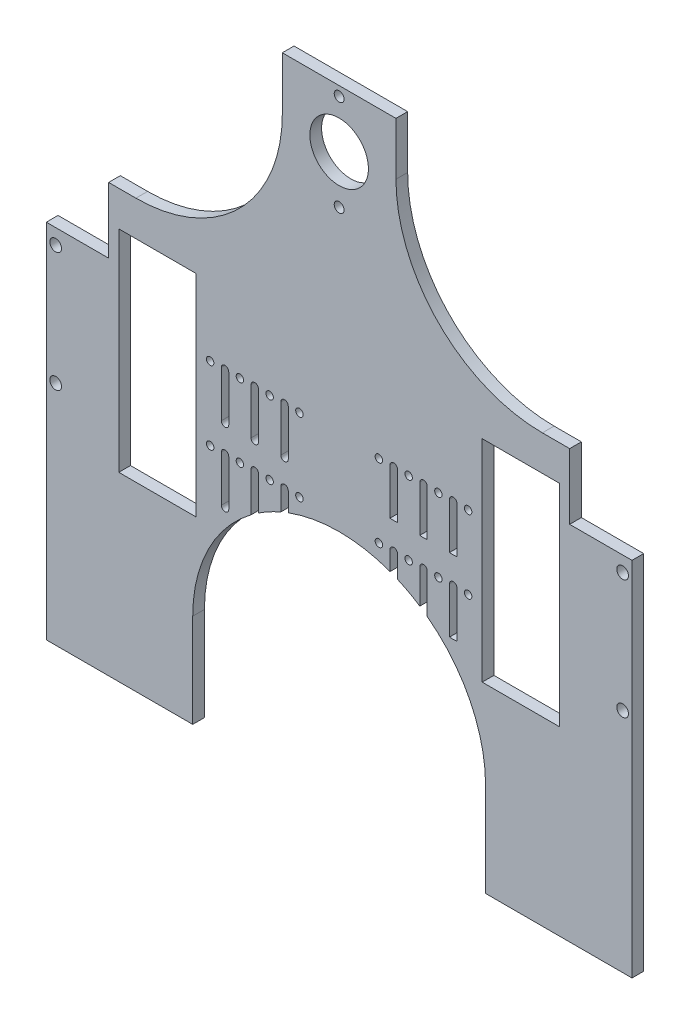
from build123d import *

# Parameters (mm, degrees)
SKETCH1_W           = 250
SKETCH1_H           = 350.4
SKETCH1_R           = 2.1
SKETCH1_R_2         = 2.5
SKETCH1_R_3         = 1.59
SKETCH1_R_4         = 12.5
SKETCH1_W_2         = 33
SKETCH1_H_2         = 90
BOSS_EXTRUDE1_DEPTH = 5
SKETCH12_W          = 250
SKETCH12_H          = 5
CUT_EXTRUDE2_DEPTH  = 83
CUT_EXTRUDE3_DEPTH  = 6
SKETCH15_W          = 20.294476706
SKETCH15_H          = 22.5
SKETCH15_W_2        = 16.246360579
CUT_EXTRUDE4_DEPTH  = 10


with BuildPart() as part:
    # Sketch1 → Boss-Extrude1 (new body)
    with BuildSketch(Plane.XY):
        with Locations((125, -175.2)):
            Rectangle(SKETCH1_W, SKETCH1_H)
        with Locations((125, -45)):
            Circle(SKETCH1_R, mode=Mode.SUBTRACT)
        with Locations((125, -4)):
            Circle(SKETCH1_R, mode=Mode.SUBTRACT)
        with Locations((246, -119.5)):
            Circle(SKETCH1_R_2, mode=Mode.SUBTRACT)
        with Locations((246, -170.5)):
            Circle(SKETCH1_R_2, mode=Mode.SUBTRACT)
        with Locations((180.06, -129.375)):
            Circle(SKETCH1_R_3, mode=Mode.SUBTRACT)
        with Locations((180.06, -160.625)):
            Circle(SKETCH1_R_3, mode=Mode.SUBTRACT)
        with Locations((125, -24.5)):
            Circle(SKETCH1_R_4, mode=Mode.SUBTRACT)
        with Locations((141.96, -129.375)):
            Circle(SKETCH1_R_3, mode=Mode.SUBTRACT)
        with Locations((154.66, -129.375)):
            Circle(SKETCH1_R_3, mode=Mode.SUBTRACT)
        with Locations((167.36, -129.375)):
            Circle(SKETCH1_R_3, mode=Mode.SUBTRACT)
        with Locations((141.96, -160.625)):
            Circle(SKETCH1_R_3, mode=Mode.SUBTRACT)
        with Locations((154.66, -160.625)):
            Circle(SKETCH1_R_3, mode=Mode.SUBTRACT)
        with Locations((167.36, -160.625)):
            Circle(SKETCH1_R_3, mode=Mode.SUBTRACT)
        with Locations((82.64, -160.625)):
            Circle(SKETCH1_R_3, mode=Mode.SUBTRACT)
        with Locations((95.34, -160.625)):
            Circle(SKETCH1_R_3, mode=Mode.SUBTRACT)
        with Locations((108.04, -160.625)):
            Circle(SKETCH1_R_3, mode=Mode.SUBTRACT)
        with Locations((82.64, -129.375)):
            Circle(SKETCH1_R_3, mode=Mode.SUBTRACT)
        with Locations((95.34, -129.375)):
            Circle(SKETCH1_R_3, mode=Mode.SUBTRACT)
        with Locations((108.04, -129.375)):
            Circle(SKETCH1_R_3, mode=Mode.SUBTRACT)
        with Locations((69.94, -160.625)):
            Circle(SKETCH1_R_3, mode=Mode.SUBTRACT)
        with Locations((69.94, -129.375)):
            Circle(SKETCH1_R_3, mode=Mode.SUBTRACT)
        with Locations((4, -170.5)):
            Circle(SKETCH1_R_2, mode=Mode.SUBTRACT)
        with Locations((4, -119.5)):
            Circle(SKETCH1_R_2, mode=Mode.SUBTRACT)
        with Locations((202.56, -145)):
            Rectangle(SKETCH1_W_2, SKETCH1_H_2, mode=Mode.SUBTRACT)
        with BuildLine():
            Line((146.7225, -129.375), (146.7225, -149.054634918))
            ThreePointArc((146.7225, -149.054634918), (148.31, -149.140223925), (149.8975, -149.054634918))
            Line((149.8975, -149.054634918), (149.8975, -129.375))
            ThreePointArc((149.8975, -129.375), (148.31, -127.7875), (146.7225, -129.375))
        make_face(mode=Mode.SUBTRACT)
        with BuildLine():
            Line((159.42, -129.375), (159.42, -149.054634918))
            ThreePointArc((159.42, -149.054634918), (161.01, -149.140492925), (162.6, -149.054634918))
            Line((162.6, -149.054634918), (162.6, -129.375))
            ThreePointArc((162.6, -129.375), (161.01, -127.785), (159.42, -129.375))
        make_face(mode=Mode.SUBTRACT)
        with BuildLine():
            Line((172.12, -129.375), (172.12, -149.054634918))
            ThreePointArc((172.12, -149.054634918), (173.71, -149.140492925), (175.3, -149.054634918))
            Line((175.3, -149.054634918), (175.3, -129.375))
            ThreePointArc((175.3, -129.375), (173.71, -127.785), (172.12, -129.375))
        make_face(mode=Mode.SUBTRACT)
        with BuildLine():
            Line((146.7225, -160.625), (146.7225, -180.304634918))
            ThreePointArc((146.7225, -180.304634918), (148.31, -180.390223925), (149.8975, -180.304634918))
            Line((149.8975, -180.304634918), (149.8975, -160.625))
            ThreePointArc((149.8975, -160.625), (148.31, -159.0375), (146.7225, -160.625))
        make_face(mode=Mode.SUBTRACT)
        with BuildLine():
            Line((159.42, -160.625), (159.42, -180.304634918))
            ThreePointArc((159.42, -180.304634918), (161.01, -180.390492925), (162.6, -180.304634918))
            Line((162.6, -180.304634918), (162.6, -160.625))
            ThreePointArc((162.6, -160.625), (161.01, -159.035), (159.42, -160.625))
        make_face(mode=Mode.SUBTRACT)
        with BuildLine():
            Line((172.12, -160.625), (172.12, -180.304634918))
            ThreePointArc((172.12, -180.304634918), (173.71, -180.390492925), (175.3, -180.304634918))
            Line((175.3, -180.304634918), (175.3, -160.625))
            ThreePointArc((175.3, -160.625), (173.71, -159.035), (172.12, -160.625))
        make_face(mode=Mode.SUBTRACT)
        with BuildLine():
            Line((103.2775, -129.375), (103.2775, -149.054634918))
            ThreePointArc((103.2775, -149.054634918), (101.69, -150.642134918), (100.1025, -149.054634918))
            Line((100.1025, -149.054634918), (100.1025, -129.375))
            ThreePointArc((100.1025, -129.375), (101.69, -127.7875), (103.2775, -129.375))
        make_face(mode=Mode.SUBTRACT)
        with BuildLine():
            Line((90.58, -129.375), (90.58, -149.054634918))
            ThreePointArc((90.58, -149.054634918), (88.99, -150.644634918), (87.4, -149.054634918))
            Line((87.4, -149.054634918), (87.4, -129.375))
            ThreePointArc((87.4, -129.375), (88.99, -127.785), (90.58, -129.375))
        make_face(mode=Mode.SUBTRACT)
        with BuildLine():
            Line((77.88, -129.375), (77.88, -149.054634918))
            ThreePointArc((77.88, -149.054634918), (76.29, -150.644634918), (74.7, -149.054634918))
            Line((74.7, -149.054634918), (74.7, -129.375))
            ThreePointArc((74.7, -129.375), (76.29, -127.785), (77.88, -129.375))
        make_face(mode=Mode.SUBTRACT)
        with BuildLine():
            Line((103.2775, -160.625), (103.2775, -180.304634918))
            ThreePointArc((103.2775, -180.304634918), (101.69, -181.892134918), (100.1025, -180.304634918))
            Line((100.1025, -180.304634918), (100.1025, -160.625))
            ThreePointArc((100.1025, -160.625), (101.69, -159.0375), (103.2775, -160.625))
        make_face(mode=Mode.SUBTRACT)
        with BuildLine():
            Line((90.58, -160.625), (90.58, -180.304634918))
            ThreePointArc((90.58, -180.304634918), (88.99, -181.894634918), (87.4, -180.304634918))
            Line((87.4, -180.304634918), (87.4, -160.625))
            ThreePointArc((87.4, -160.625), (88.99, -159.035), (90.58, -160.625))
        make_face(mode=Mode.SUBTRACT)
        with BuildLine():
            Line((77.88, -160.625), (77.88, -180.304634918))
            ThreePointArc((77.88, -180.304634918), (76.29, -181.894634918), (74.7, -180.304634918))
            Line((74.7, -180.304634918), (74.7, -160.625))
            ThreePointArc((74.7, -160.625), (76.29, -159.035), (77.88, -160.625))
        make_face(mode=Mode.SUBTRACT)
        with Locations((47.44, -145)):
            Rectangle(SKETCH1_W_2, SKETCH1_H_2, mode=Mode.SUBTRACT)
    extrude(amount=BOSS_EXTRUDE1_DEPTH)

    # Sketch12 → Cut-Extrude2 (cut)
    with BuildSketch(Plane.XZ.offset(350.4)):
        with Locations((125, 2.5)):
            Rectangle(SKETCH12_W, SKETCH12_H)
    extrude(amount=-CUT_EXTRUDE2_DEPTH, mode=Mode.SUBTRACT)

    # Sketch13 → Cut-Extrude3 (cut, through all)
    with BuildSketch(Plane.XY.offset(5)):
        with BuildLine():
            Line((38.250392508, -85), (26.604338358, -85))
            Line((26.604338358, -85), (26.604338358, -113))
            Line((26.604338358, -113), (0, -113))
            Line((0, -113), (0, 0))
            Line((0, 0), (96.559911457, 0))
            ThreePointArc((96.559911457, 0), (89.789212828, -57.855339059), (38.250392508, -85))
        make_face()
        with BuildLine():
            Line((250, 0), (250, -113))
            Line((250, -113), (223.395661642, -113))
            Line((223.395661642, -113), (223.395661642, -85))
            Line((223.395661642, -85), (211.749607492, -85))
            ThreePointArc((211.749607492, -85), (160.210787172, -57.855339059), (153.440088543, 0))
            Line((153.440088543, 0), (250, 0))
        make_face()
        with BuildLine():
            Line((62.5, -227.4), (62.5, -350.4))
            Line((62.5, -350.4), (187.5, -350.4))
            Line((187.5, -350.4), (187.5, -227.4))
            ThreePointArc((187.5, -227.4), (125, -164.9), (62.5, -227.4))
        make_face()
    extrude(amount=-CUT_EXTRUDE3_DEPTH, mode=Mode.SUBTRACT)

    # Sketch15 → Cut-Extrude4 (cut)
    with BuildSketch(Plane.XY.offset(5)):
        with Locations((90.603154155, -11.25)):
            Rectangle(SKETCH15_W, SKETCH15_H)
        with Locations((157.372787781, -11.25)):
            Rectangle(SKETCH15_W_2, SKETCH15_H)
    extrude(amount=-CUT_EXTRUDE4_DEPTH, mode=Mode.SUBTRACT)


solid = part.part
